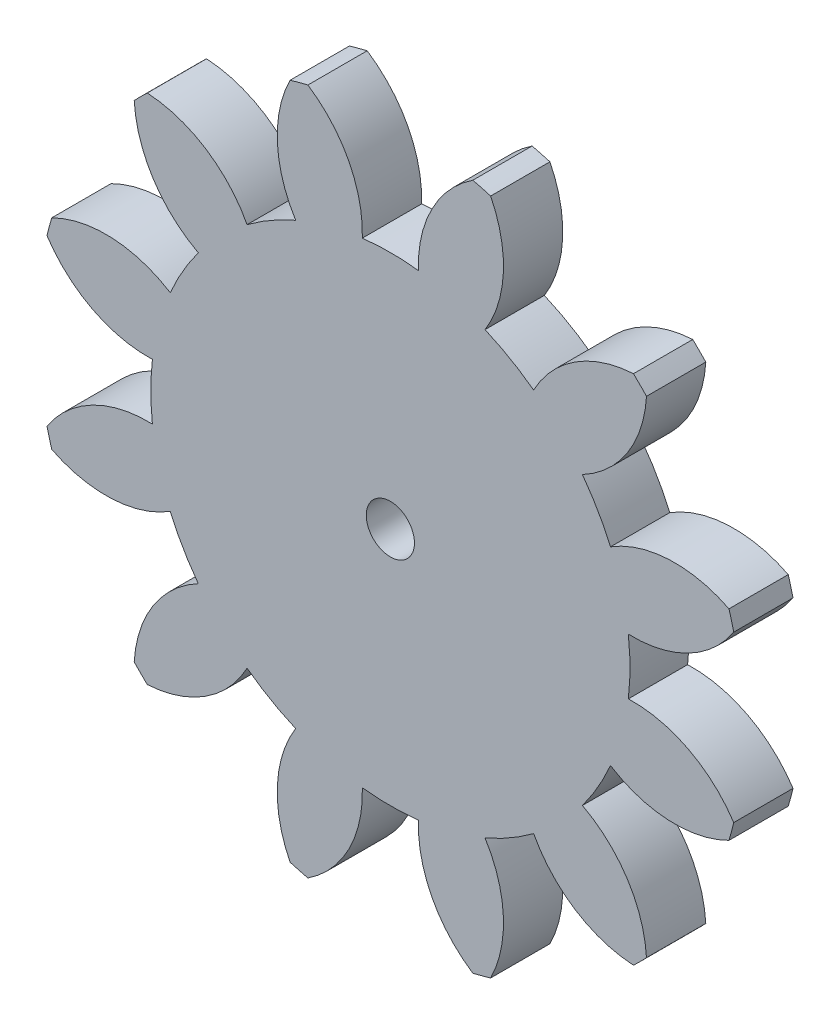
from build123d import *

# Parameters (mm, degrees)
SKETCH1_R           = 0.955
BOSS_EXTRUDE1_DEPTH = 2.35


with BuildPart() as part:
    # Sketch1 → Boss-Extrude1 (new body)
    with BuildSketch(Plane.XY):
        with BuildLine():
            ThreePointArc((31.089190509, -0.00961289), (28.777823425, -0.762116774), (27.131493603, -2.550489779))
            ThreePointArc((27.131493603, -2.550489779), (26.201203233, -1.937982234), (25.205610954, -1.438580913))
            ThreePointArc((25.205610954, -1.438580913), (25.931222497, 0.881369039), (25.427226435, 3.259323592))
            ThreePointArc((25.427226435, 3.259323592), (25.075169864, 3.358604023), (24.720639715, 3.448652933))
            ThreePointArc((24.720639715, 3.448652933), (23.095189045, 1.641281911), (22.563612099, -0.730659454))
            ThreePointArc((22.563612099, -0.730659454), (21.451703233, -0.665357545), (20.339794367, -0.730659454))
            ThreePointArc((20.339794367, -0.730659454), (19.80821742, 1.641281911), (18.182766751, 3.448652933))
            ThreePointArc((18.182766751, 3.448652933), (17.828236601, 3.358604023), (17.47618003, 3.259323592))
            ThreePointArc((17.47618003, 3.259323592), (16.972183969, 0.881369039), (17.697795512, -1.438580913))
            ThreePointArc((17.697795512, -1.438580913), (16.702203233, -1.937982234), (15.771912863, -2.550489779))
            ThreePointArc((15.771912863, -2.550489779), (14.12558304, -0.762116774), (11.814215957, -0.00961289))
            ThreePointArc((11.814215957, -0.00961289), (11.552208296, -0.264862608), (11.296958578, -0.526870269))
            ThreePointArc((11.296958578, -0.526870269), (12.049462462, -2.838237352), (13.837835467, -4.484567174))
            ThreePointArc((13.837835467, -4.484567174), (13.225327922, -5.414857545), (12.725926601, -6.410449824))
            ThreePointArc((12.725926601, -6.410449824), (10.40597665, -5.684838281), (8.028022096, -6.188834342))
            ThreePointArc((8.028022096, -6.188834342), (7.928741665, -6.540890913), (7.838692755, -6.895421063))
            ThreePointArc((7.838692755, -6.895421063), (9.646063777, -8.520871732), (12.018005142, -9.052448679))
            ThreePointArc((12.018005142, -9.052448679), (11.952703233, -10.164357545), (12.018005142, -11.276266411))
            ThreePointArc((12.018005142, -11.276266411), (9.646063777, -11.807843357), (7.838692755, -13.433294027))
            ThreePointArc((7.838692755, -13.433294027), (7.928741665, -13.787824176), (8.028022096, -14.139880747))
            ThreePointArc((8.028022096, -14.139880747), (10.40597665, -14.643876808), (12.725926601, -13.918265265))
            ThreePointArc((12.725926601, -13.918265265), (13.225327922, -14.913857545), (13.837835467, -15.844147915))
            ThreePointArc((13.837835467, -15.844147915), (12.049462462, -17.490477737), (11.296958578, -19.80184482))
            ThreePointArc((11.296958578, -19.80184482), (11.552208296, -20.063852481), (11.814215957, -20.3191022))
            ThreePointArc((11.814215957, -20.3191022), (14.12558304, -19.566598315), (15.771912863, -17.77822531))
            ThreePointArc((15.771912863, -17.77822531), (16.702203233, -18.390732855), (17.697795512, -18.890134176))
            ThreePointArc((17.697795512, -18.890134176), (16.972183969, -21.210084128), (17.47618003, -23.588038682))
            ThreePointArc((17.47618003, -23.588038682), (17.828236601, -23.687319113), (18.182766751, -23.777368023))
            ThreePointArc((18.182766751, -23.777368023), (19.80821742, -21.969997001), (20.339794367, -19.598055636))
            ThreePointArc((20.339794367, -19.598055636), (21.451703233, -19.663357545), (22.563612099, -19.598055636))
            ThreePointArc((22.563612099, -19.598055636), (23.095189045, -21.969997001), (24.720639715, -23.777368023))
            ThreePointArc((24.720639715, -23.777368023), (25.075169864, -23.687319113), (25.427226435, -23.588038682))
            ThreePointArc((25.427226435, -23.588038682), (25.931222497, -21.210084128), (25.205610954, -18.890134176))
            ThreePointArc((25.205610954, -18.890134176), (26.201203233, -18.390732855), (27.131493603, -17.77822531))
            ThreePointArc((27.131493603, -17.77822531), (28.777823425, -19.566598315), (31.089190509, -20.3191022))
            ThreePointArc((31.089190509, -20.3191022), (31.351198169, -20.063852481), (31.606447888, -19.80184482))
            ThreePointArc((31.606447888, -19.80184482), (30.853944004, -17.490477737), (29.065570998, -15.844147915))
            ThreePointArc((29.065570998, -15.844147915), (29.678078543, -14.913857545), (30.177479864, -13.918265265))
            ThreePointArc((30.177479864, -13.918265265), (32.497429816, -14.643876808), (34.87538437, -14.139880747))
            ThreePointArc((34.87538437, -14.139880747), (34.974664801, -13.787824176), (35.064713711, -13.433294027))
            ThreePointArc((35.064713711, -13.433294027), (33.257342689, -11.807843357), (30.885401324, -11.276266411))
            ThreePointArc((30.885401324, -11.276266411), (30.950703233, -10.164357545), (30.885401324, -9.052448679))
            ThreePointArc((30.885401324, -9.052448679), (33.257342689, -8.520871732), (35.064713711, -6.895421063))
            ThreePointArc((35.064713711, -6.895421063), (34.974664801, -6.540890913), (34.87538437, -6.188834342))
            ThreePointArc((34.87538437, -6.188834342), (32.497429816, -5.684838281), (30.177479864, -6.410449824))
            ThreePointArc((30.177479864, -6.410449824), (29.678078543, -5.414857545), (29.065570998, -4.484567174))
            ThreePointArc((29.065570998, -4.484567174), (30.853944004, -2.838237352), (31.606447888, -0.526870269))
            ThreePointArc((31.606447888, -0.526870269), (31.351198169, -0.264862608), (31.089190509, -0.00961289))
        make_face()
        with Locations((21.451703233, -10.164357545)):
            Circle(SKETCH1_R, mode=Mode.SUBTRACT)
    extrude(amount=BOSS_EXTRUDE1_DEPTH)


solid = part.part
